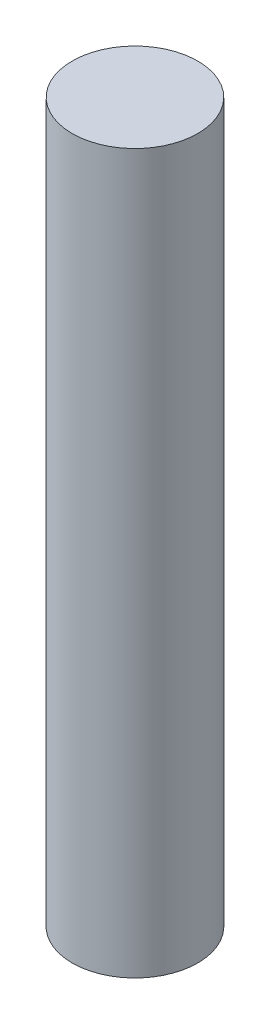
from build123d import *

# Parameters (mm, degrees)
SKETCH2_R           = 13.115
BOSS_EXTRUDE1_DEPTH = 75


with BuildPart() as part:
    # Sketch2 → Boss-Extrude1 (new body, symmetric)
    with BuildSketch(Plane(origin=(0, 0, 0), x_dir=(1, 0, 0), z_dir=(0, 1, 0))):
        Circle(SKETCH2_R)
    extrude(amount=BOSS_EXTRUDE1_DEPTH, both=True)


solid = part.part
